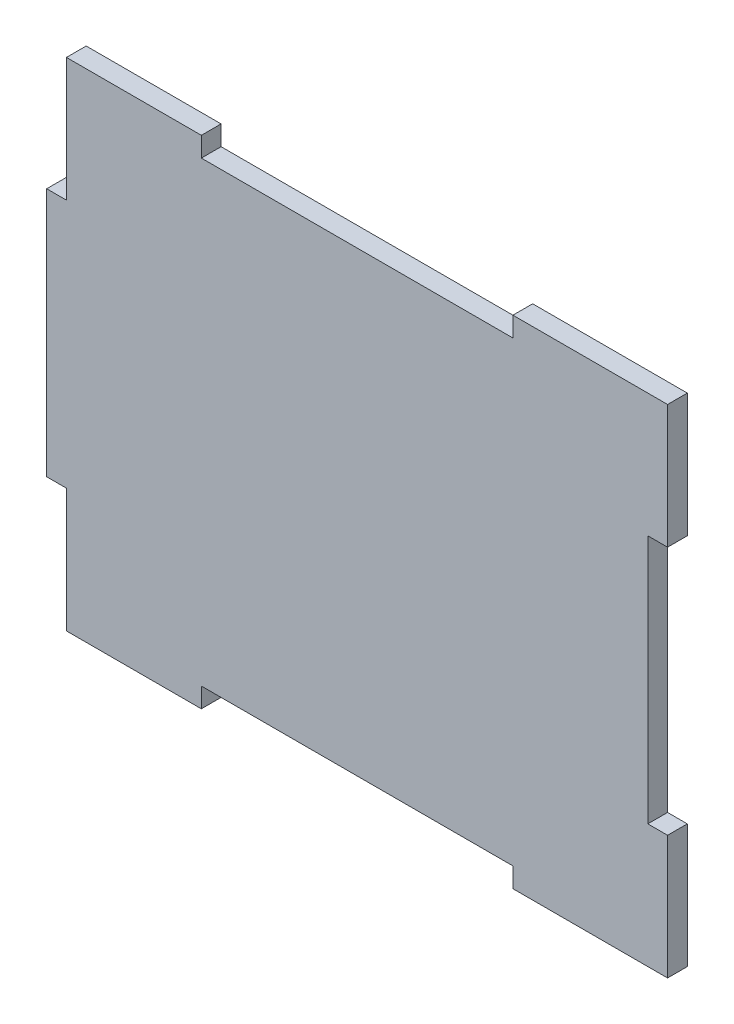
from build123d import *

# Parameters (mm, degrees)
SKETCH3_W           = 100
SKETCH3_H           = 80
BOSS_EXTRUDE1_DEPTH = 3.18
SKETCH4_W           = 50.18
SKETCH4_H           = 3.18
CUT_EXTRUDE1_DEPTH  = 3.18
SKETCH5_W           = 3.18
SKETCH5_H           = 40.18
CUT_EXTRUDE2_DEPTH  = 3.18
SKETCH6_W           = 3.18
SKETCH6_H           = 19.91
CUT_EXTRUDE3_DEPTH  = 3.18


with BuildPart() as part:
    # Sketch3 → Boss-Extrude1 (new body)
    with BuildSketch(Plane.XY):
        Rectangle(SKETCH3_W, SKETCH3_H)
    extrude(amount=BOSS_EXTRUDE1_DEPTH)

    # Sketch4 → Cut-Extrude1 (cut)
    with BuildSketch(Plane.XY.offset(3.18)):
        with Locations((0, 38.41)):
            Rectangle(SKETCH4_W, SKETCH4_H)
    cut_extrude1 = extrude(amount=-CUT_EXTRUDE1_DEPTH, mode=Mode.SUBTRACT)

    # Mirror1: Cut-Extrude1 across plane
    add(cut_extrude1.mirror(Plane.ZX), mode=Mode.SUBTRACT)

    # Sketch5 → Cut-Extrude2 (cut)
    with BuildSketch(Plane.XY.offset(3.18)):
        with Locations((48.41, 0)):
            Rectangle(SKETCH5_W, SKETCH5_H)
    extrude(amount=-CUT_EXTRUDE2_DEPTH, mode=Mode.SUBTRACT)

    # Sketch6 → Cut-Extrude3 (cut)
    with BuildSketch(Plane.XY.offset(3.18)):
        with Locations((-48.41, 30.045)):
            Rectangle(SKETCH6_W, SKETCH6_H)
    cut_extrude3 = extrude(amount=-CUT_EXTRUDE3_DEPTH, mode=Mode.SUBTRACT)

    # Mirror2: Cut-Extrude3 across plane
    add(cut_extrude3.mirror(Plane.ZX), mode=Mode.SUBTRACT)


solid = part.part
